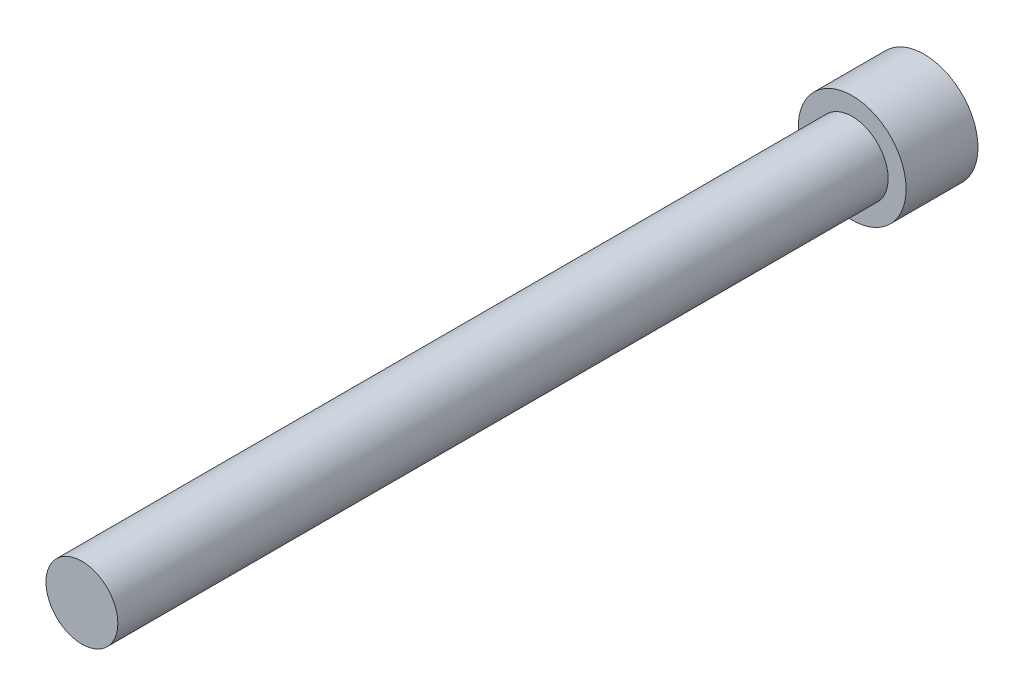
from build123d import *

# Parameters (mm, degrees)
SKETCH_1_R      = 10.5
EXTRUDE_1_DEPTH = 14
SKETCH_2_R      = 7
EXTRUDE_2_DEPTH = 150


with BuildPart() as part:
    # 草图1 → 凸台-拉伸1 (new body)
    with BuildSketch(Plane.XY):
        with Locations((-16.410483799, 16.544995961)):
            Circle(SKETCH_1_R)
    extrude(amount=EXTRUDE_1_DEPTH)

    # 草图2 → 凸台-拉伸2 (add)
    with BuildSketch(Plane.XY.offset(14)):
        with Locations((-16.410483799, 16.544995961)):
            Circle(SKETCH_2_R)
    extrude(amount=EXTRUDE_2_DEPTH)


solid = part.part
